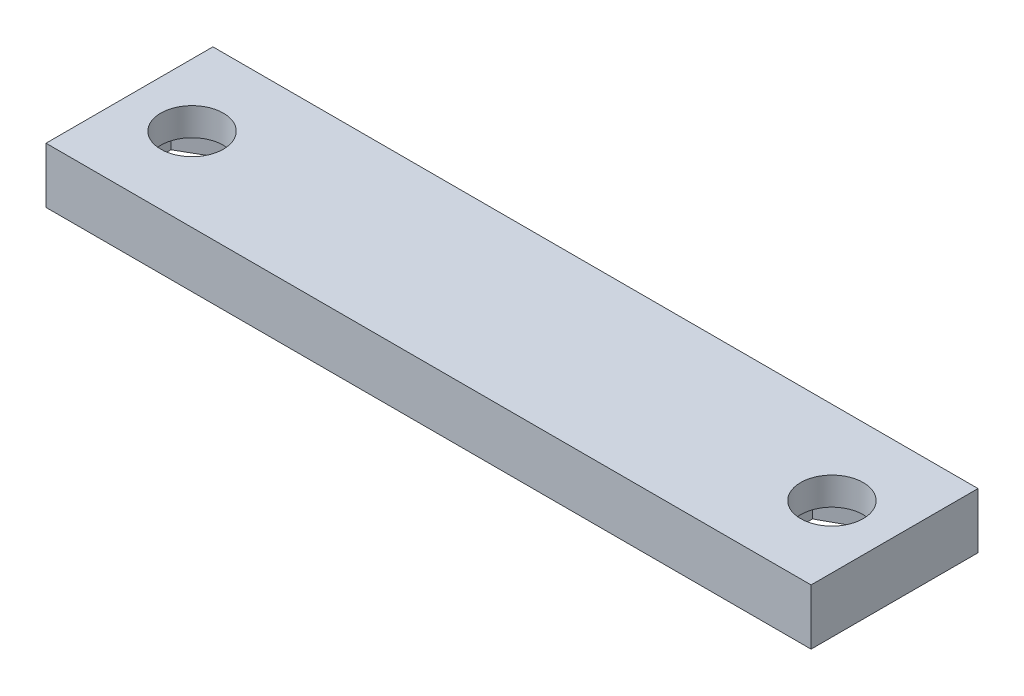
from build123d import *

# Parameters (mm, degrees)
SKETCH1_W           = 55
SKETCH1_H           = 12
SKETCH1_R           = 2.25
BOSS_EXTRUDE1_DEPTH = 4
CUT_EXTRUDE1_DEPTH  = 2


with BuildPart() as part:
    # Sketch1 → Boss-Extrude1 (new body)
    with BuildSketch(Plane(origin=(0, 0, 0), x_dir=(1, 0, 0), z_dir=(0, 1, 0))):
        Rectangle(SKETCH1_W, SKETCH1_H)
        with Locations((-23, 0)):
            Circle(SKETCH1_R, mode=Mode.SUBTRACT)
        with Locations((23, 0)):
            Circle(SKETCH1_R, mode=Mode.SUBTRACT)
    extrude(amount=BOSS_EXTRUDE1_DEPTH)

    # Sketch2 → Cut-Extrude1 (cut)
    with BuildSketch(Plane(origin=(0, 0, 0), x_dir=(-1, 0, 0), z_dir=(0, -1, 0))):
        Polygon((-19.449221668, 2.161474783), (-23.096502906, 4.15580163), (-26.647281238, 1.994326847), (-26.550778332, -2.161474783), (-22.903497094, -4.15580163), (-19.352718762, -1.994326847), align=None)
        Polygon((23, 4.156921938), (19.4, 2.078460969), (19.4, -2.078460969), (23, -4.156921938), (26.6, -2.078460969), (26.6, 2.078460969), align=None)
    extrude(amount=-CUT_EXTRUDE1_DEPTH, mode=Mode.SUBTRACT)


solid = part.part
